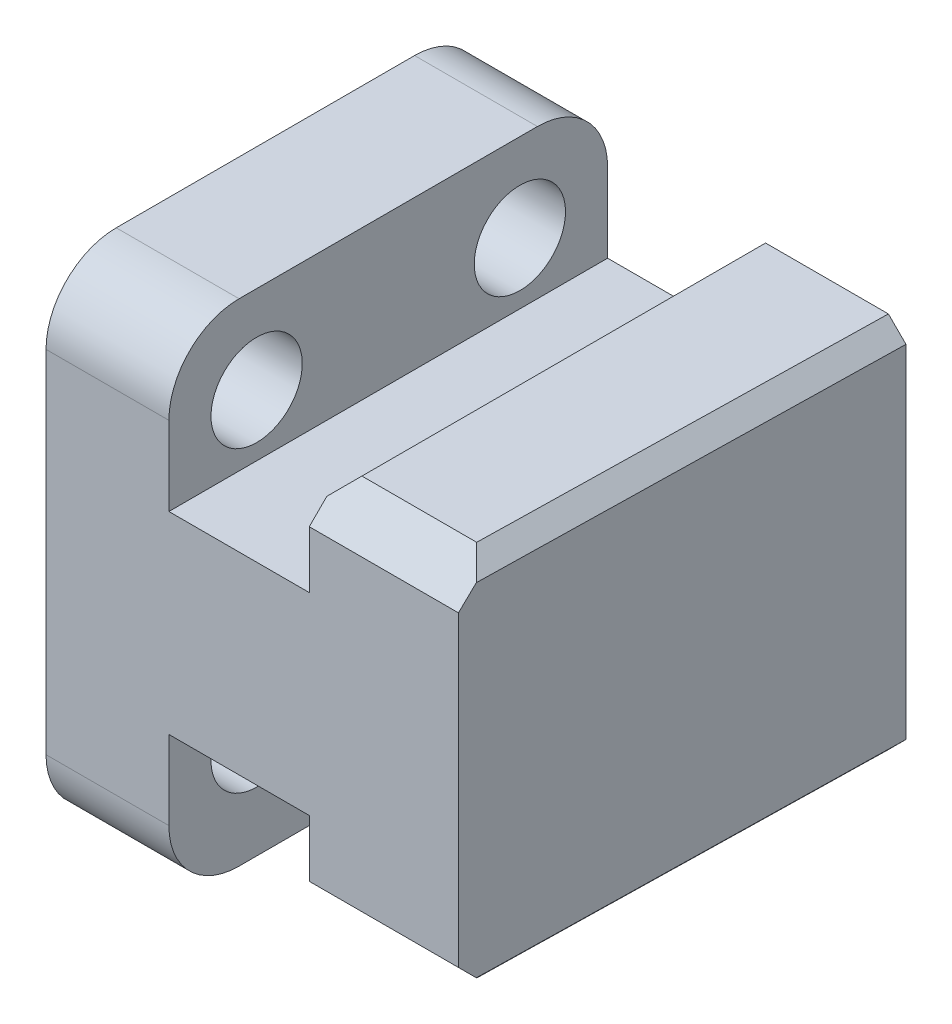
from build123d import *

# Parameters (mm, degrees)
BOSS_EXTRUDE1_DEPTH = 25
SKETCH2_R           = 2.6
CUT_EXTRUDE1_DEPTH  = 8
CUT_EXTRUDE2_DEPTH  = 25.75
FILLET1_R           = 4
CHAMFER1_SIZE       = 2
CHAMFER2_SIZE       = 1


with BuildPart() as part:
    # Sketch1 → Boss-Extrude1 (new body)
    with BuildSketch(Plane.XY):
        Polygon((0, 14), (0, -14), (7, -14), (7, -5.5), (15, -5.5), (15, -10.75), (24, -10.75), (24, 10.75), (15, 10.75), (15, 5.5), (7, 5.5), (7, 14), align=None)
    extrude(amount=BOSS_EXTRUDE1_DEPTH)

    # Sketch2 → Cut-Extrude1 (cut)
    with BuildSketch(Plane.ZY):
        with Locations(Location((5, 9, 0), (0, 0, 270))):  # turned: the seam where the file's is
            Circle(SKETCH2_R)
        with Locations(Location((20, 9, 0), (0, 0, 270))):  # turned: the seam where the file's is
            Circle(SKETCH2_R)
        with Locations(Location((5, -8, 0), (0, 0, 270))):  # turned: the seam where the file's is
            Circle(SKETCH2_R)
        with Locations(Location((20, -8, 0), (0, 0, 270))):  # turned: the seam where the file's is
            Circle(SKETCH2_R)
    extrude(amount=-CUT_EXTRUDE1_DEPTH, mode=Mode.SUBTRACT)

    # Sketch3 → Cut-Extrude2 (cut, through all)
    with BuildSketch(Plane(origin=(0, 10.75, 0), x_dir=(1, 0, 0), z_dir=(0, 1, 0))):
        Polygon((24, 0), (23.5, -25), (24, -25), align=None)
    extrude(amount=-CUT_EXTRUDE2_DEPTH, mode=Mode.SUBTRACT)

    # Fillet1
    fillet1_edges = [part.edges().sort_by_distance(p)[0] for p in [
        (3.5, -14, 25),
        (3.5, -14, 0),
        (3.5, 14, 0),
        (3.5, 14, 25),
    ]]
    fillet(fillet1_edges, radius=FILLET1_R)

    # Chamfer1
    chamfer1_edges = [part.edges().sort_by_distance(p)[0] for p in [
        (19.25, -10.75, 25),
        (19.25, 10.75, 25),
    ]]
    chamfer(chamfer1_edges, length=CHAMFER1_SIZE)

    # Chamfer2
    chamfer2_edges = [part.edges().sort_by_distance(p)[0] for p in [
        (15, -10.75, 11.5),
        (15, 10.75, 11.5),
        (23.77, -10.75, 11.5),
        (23.77, 10.75, 11.5),
    ]]
    chamfer(chamfer2_edges, length=CHAMFER2_SIZE)


solid = part.part
